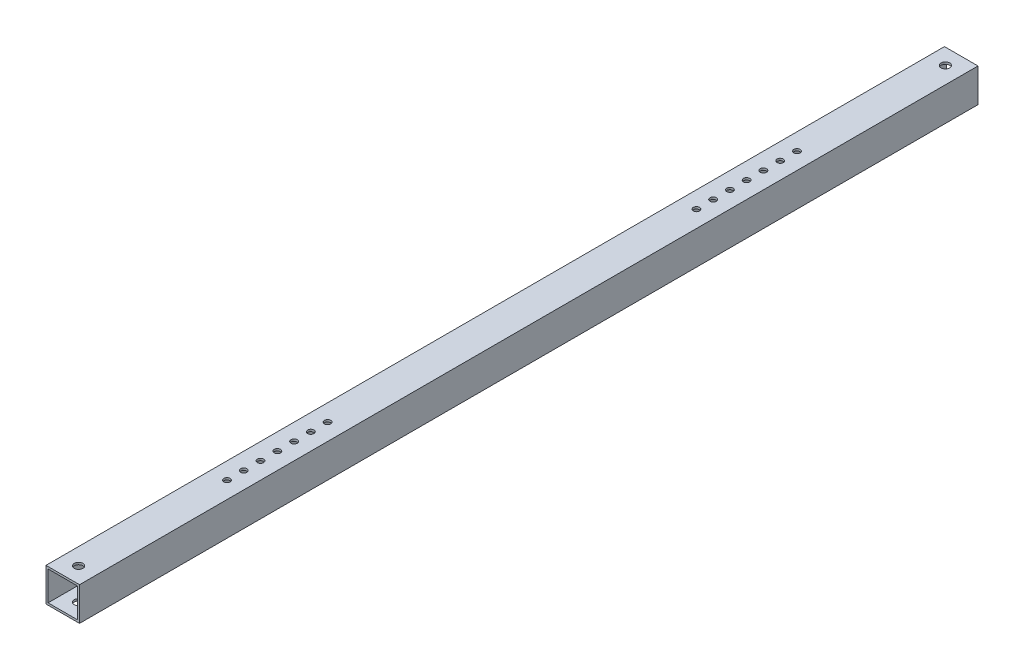
from build123d import *

# Parameters (mm, degrees)
SKETCH1_W            = 25.4
SKETCH1_H            = 25.4
BOSS_EXTRUDE1_DEPTH  = 340.36
SKETCH2_W            = 22.225
SKETCH2_H            = 22.225
CUT_EXTRUDE1_DEPTH   = 681.72
SKETCH3_R            = 2.38125
CUT_EXTRUDE2_DEPTH   = 26.4
M6_CLEARANCE_HOLE1_D = 6.6


with BuildPart() as part:
    # Sketch1 → Boss-Extrude1 (new body, symmetric)
    with BuildSketch(Plane.XY):
        Rectangle(SKETCH1_W, SKETCH1_H)
    extrude(amount=BOSS_EXTRUDE1_DEPTH, both=True)

    # Sketch2 → Cut-Extrude1 (cut, through all)
    with BuildSketch(Plane.XY.offset(340.36)):
        Rectangle(SKETCH2_W, SKETCH2_H)
    extrude(amount=-CUT_EXTRUDE1_DEPTH, mode=Mode.SUBTRACT)

    # Sketch3 → Cut-Extrude2 (cut, through all)
    with BuildSketch(Plane(origin=(0, 12.7, 0), x_dir=(1, 0, 0), z_dir=(0, 1, 0))):
        with Locations((0, -215.9)):
            Circle(SKETCH3_R)
        with Locations((0, -203.2)):
            Circle(SKETCH3_R)
        with Locations((0, -190.5)):
            Circle(SKETCH3_R)
        with Locations((0, -177.8)):
            Circle(SKETCH3_R)
        with Locations((0, -165.1)):
            Circle(SKETCH3_R)
        with Locations((0, -152.4)):
            Circle(SKETCH3_R)
        with Locations((0, -139.7)):
            Circle(SKETCH3_R)
        with Locations((0, 139.7)):
            Circle(SKETCH3_R)
        with Locations((0, 152.4)):
            Circle(SKETCH3_R)
        with Locations((0, 165.1)):
            Circle(SKETCH3_R)
        with Locations((0, 177.8)):
            Circle(SKETCH3_R)
        with Locations((0, 190.5)):
            Circle(SKETCH3_R)
        with Locations((0, 215.9)):
            Circle(SKETCH3_R)
        with Locations((0, 203.2)):
            Circle(SKETCH3_R)
    extrude(amount=-CUT_EXTRUDE2_DEPTH, mode=Mode.SUBTRACT)

    # M6 Clearance Hole1 (through all)
    with Locations(Plane(origin=(0, 12.7, 0), x_dir=(1, 0, 0), z_dir=(0, 1, 0))):
        with Locations((0, 328.36), (0, -328.36)):
            Hole(M6_CLEARANCE_HOLE1_D / 2)


solid = part.part
